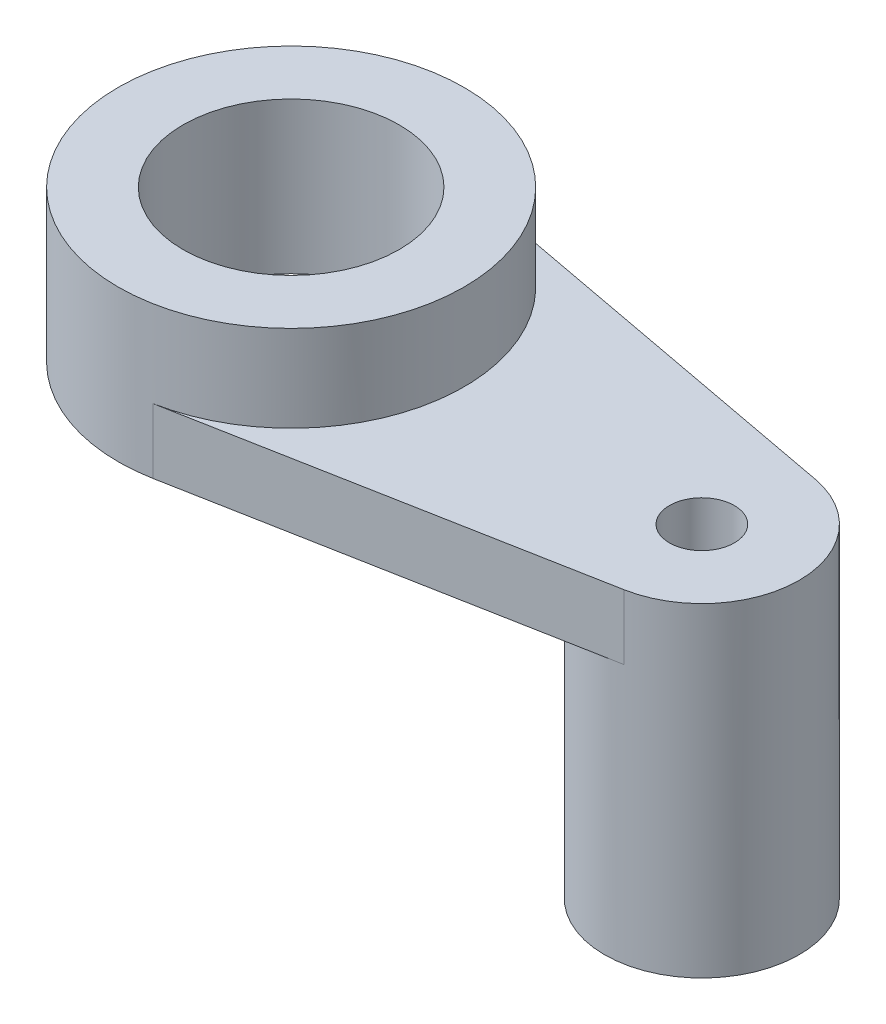
from build123d import *

# Parameters (mm, degrees)
SKETCH3_R           = 16
SKETCH3_R_2         = 9.000000001
BOSS_EXTRUDE1_DEPTH = 6
SKETCH4_R           = 9
BOSS_EXTRUDE2_DEPTH = 30
SKETCH5_R           = 16
BOSS_EXTRUDE3_DEPTH = 8
SKETCH6_R           = 10
CUT_EXTRUDE1_DEPTH  = 39
SKETCH7_R           = 3
CUT_EXTRUDE2_DEPTH  = 31


with BuildPart() as part:
    # Sketch3 → Boss-Extrude1 (new body)
    with BuildSketch(Plane(origin=(0, 0, 0), x_dir=(1, 0, 0), z_dir=(0, 1, 0))):
        Circle(SKETCH3_R)
        with BuildLine():
            Line((39.657894736, 8.845981293), (2.947368421, 15.726188966))
            ThreePointArc((2.947368421, 15.726188966), (12.311740225, 10.218661979), (16, 0))
            ThreePointArc((16, 0), (12.311740225, -10.218661979), (2.947368421, -15.726188966))
            Line((2.947368421, -15.726188966), (39.657894736, -8.845981293))
            ThreePointArc((39.657894736, -8.845981294), (28.999999998, 0), (39.657894736, 8.845981294))
        make_face()
        with Locations((37.999999999, 0)):
            Circle(SKETCH3_R_2)
    extrude(amount=BOSS_EXTRUDE1_DEPTH)

    # Sketch4 → Boss-Extrude2 (add)
    with BuildSketch(Plane(origin=(0, 6, 0), x_dir=(1, 0, 0), z_dir=(0, 1, 0))):
        with Locations((38, 0)):
            Circle(SKETCH4_R)
    extrude(amount=-BOSS_EXTRUDE2_DEPTH)

    # Sketch5 → Boss-Extrude3 (add)
    with BuildSketch(Plane(origin=(0, 6, 0), x_dir=(1, 0, 0), z_dir=(0, 1, 0))):
        Circle(SKETCH5_R)
    extrude(amount=BOSS_EXTRUDE3_DEPTH)

    # Sketch6 → Cut-Extrude1 (cut, through all)
    with BuildSketch(Plane(origin=(0, 14, 0), x_dir=(1, 0, 0), z_dir=(0, 1, 0))):
        Circle(SKETCH6_R)
    extrude(amount=-CUT_EXTRUDE1_DEPTH, mode=Mode.SUBTRACT)

    # Sketch7 → Cut-Extrude2 (cut, through all)
    with BuildSketch(Plane(origin=(0, 6, 0), x_dir=(1, 0, 0), z_dir=(0, 1, 0))):
        with Locations((38, 0)):
            Circle(SKETCH7_R)
    extrude(amount=-CUT_EXTRUDE2_DEPTH, mode=Mode.SUBTRACT)


solid = part.part
